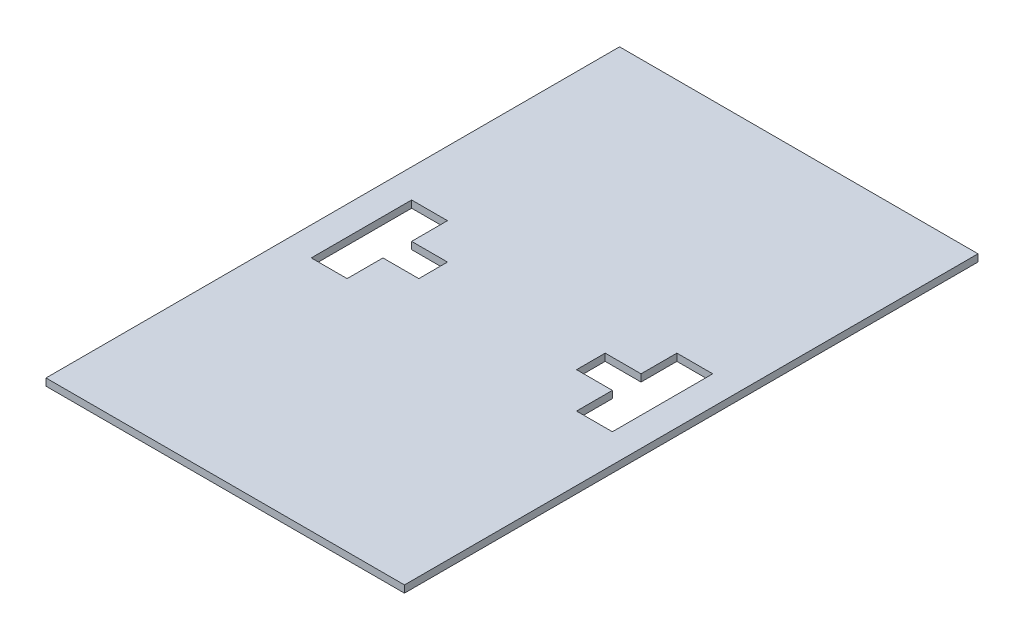
from build123d import *

# Parameters (mm, degrees)
SKETCH1_W           = 500
SKETCH1_H           = 800
BOSS_EXTRUDE1_DEPTH = 10
CUT_EXTRUDE1_DEPTH  = 10


with BuildPart() as part:
    # Sketch1 → Boss-Extrude1 (new body)
    with BuildSketch(Plane(origin=(0, 0, 0), x_dir=(1, 0, 0), z_dir=(0, 1, 0))):
        Rectangle(SKETCH1_W, SKETCH1_H)
    extrude(amount=BOSS_EXTRUDE1_DEPTH)

    # Sketch2 → Cut-Extrude1 (cut)
    with BuildSketch(Plane(origin=(0, 10, 0), x_dir=(1, 0, 0), z_dir=(0, 1, 0))):
        Polygon((-160, -70), (-210, -70), (-210, 70), (-160, 70), (-160, 20), (-110, 20), (-110, -20), (-160, -20), align=None)
    cut_extrude1 = extrude(amount=-CUT_EXTRUDE1_DEPTH, mode=Mode.SUBTRACT)

    # Mirror1: Cut-Extrude1 across plane
    add(cut_extrude1.mirror(Plane(origin=(0, 0, 0), x_dir=(0, 0, 1), z_dir=(1, 0, 0))), mode=Mode.SUBTRACT)


solid = part.part
